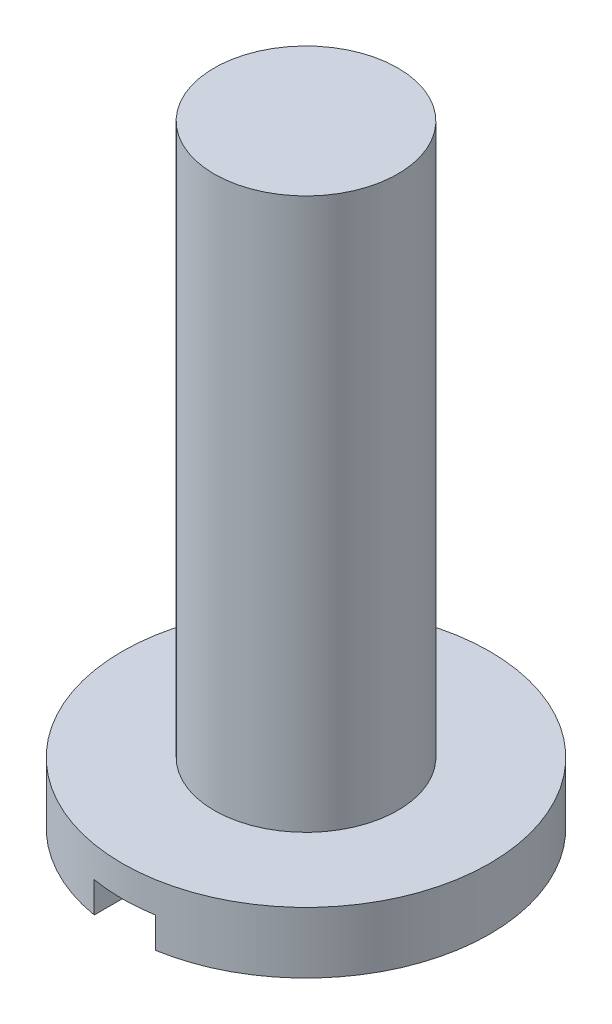
from build123d import *

# Parameters (mm, degrees)
ESQUISSE2_W             = 1
ESQUISSE2_H             = 6
ENL_V_MAT_EXTRU_1_DEPTH = 0.5


with BuildPart() as part:
    # Esquisse1 → Révolution1 (revolve)
    with BuildSketch(Plane.XY):
        Polygon((0, 0), (3, 0), (3, 1), (1.5, 1), (1.5, 10), (0, 10), align=None)
    revolve(axis=Axis((0, 0, 0), (0, 1, 0)))

    # Esquisse2 → Enlèv. mat.-Extru.1 (cut)
    with BuildSketch(Plane.XZ):
        Rectangle(ESQUISSE2_W, ESQUISSE2_H)
    extrude(amount=-ENL_V_MAT_EXTRU_1_DEPTH, mode=Mode.SUBTRACT)


solid = part.part
